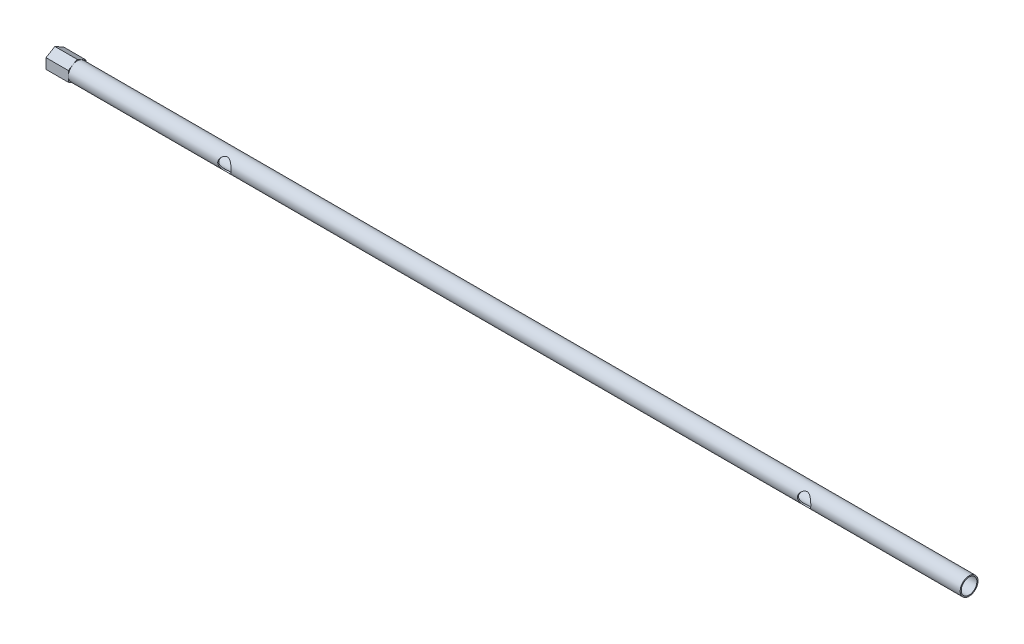
from build123d import *

# Parameters (mm, degrees)
SWEEP1_PROFILE_R    = 2
BOSS_EXTRUDE1_DEPTH = 5
SKETCH10_R          = 1.75
CUT_EXTRUDE1_DEPTH  = 200
SKETCH35_R          = 1.5
CUT_EXTRUDE3_DEPTH  = 10


with BuildPart() as part:
    # Sweep1: sweep along a path in Sketch2
    with BuildLine(Plane(origin=(0, 0, 0), x_dir=(1, 0, 0), z_dir=(0, 1, 0))) as sweep1_path:
        Line((-100, 0), (100, 0))
    # Sweep1 profile (on start of the path) → Sweep1 (sweep)
    with BuildSketch(Plane(origin=(-100, 0, 0), x_dir=(0, 0, 1), z_dir=(1, 0, 0))):
        Circle(SWEEP1_PROFILE_R)
    sweep(path=sweep1_path.line)

    # Sketch9 → Boss-Extrude1 (add)
    with BuildSketch(Plane.ZY.offset(100)):
        Polygon((1.98826653, -1.174789146), (2.01153051, 1.134494752), (0.023263979, 2.309283898), (-1.98826653, 1.174789146), (-2.01153051, -1.134494752), (-0.023263979, -2.309283898), align=None)
    extrude(amount=BOSS_EXTRUDE1_DEPTH)

    # Sketch10 → Cut-Extrude1 (cut)
    with BuildSketch(Plane(origin=(100, 0, 0), x_dir=(0, 0, -1), z_dir=(1, 0, 0))):
        Circle(SKETCH10_R)
    extrude(amount=-CUT_EXTRUDE1_DEPTH, mode=Mode.SUBTRACT)

    # Sketch35 → Cut-Extrude3 (cut)
    with BuildSketch(Plane.XY.offset(2)):
        with Locations((65, 0)):
            Circle(SKETCH35_R)
        with Locations((-65, 0)):
            Circle(SKETCH35_R)
    extrude(amount=-CUT_EXTRUDE3_DEPTH, mode=Mode.SUBTRACT)


solid = part.part
